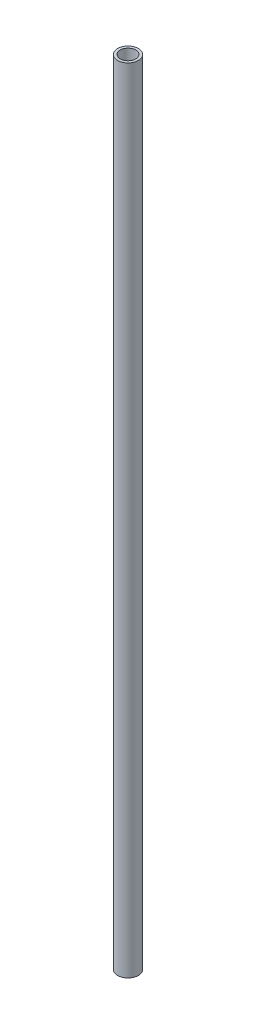
from build123d import *

# Parameters (mm, degrees)
SKETCH1_R           = 2
SKETCH1_R_2         = 1.5
BOSS_EXTRUDE1_DEPTH = 76.5


with BuildPart() as part:
    # Sketch1 → Boss-Extrude1 (new body, symmetric)
    with BuildSketch(Plane(origin=(0, 0, 0), x_dir=(1, 0, 0), z_dir=(0, 1, 0))):
        Circle(SKETCH1_R)
        Circle(SKETCH1_R_2, mode=Mode.SUBTRACT)
    extrude(amount=BOSS_EXTRUDE1_DEPTH, both=True)


solid = part.part
